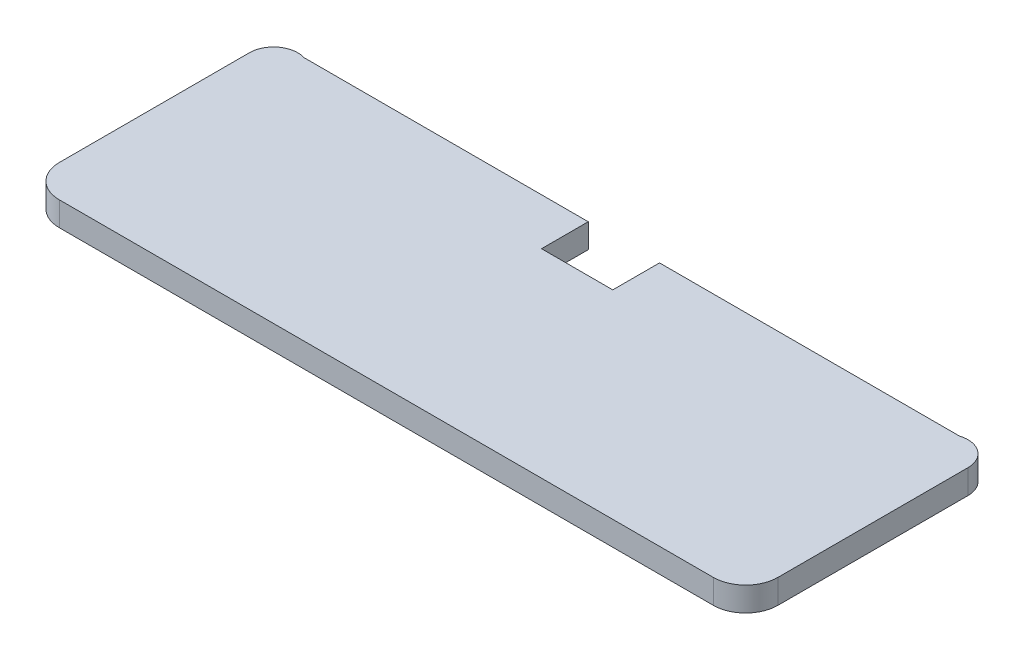
from build123d import *

# Parameters (mm, degrees)
RESSALTO_EXTRUS_O1_DEPTH = 3


with BuildPart() as part:
    # Esboço1 → Ressalto-extrusão1 (new body)
    with BuildSketch(Plane(origin=(0, 0, 0), x_dir=(1, 0, 0), z_dir=(0, 1, 0))):
        with BuildLine():
            Line((37.16356961, 16.484544918), (0, 16.484544918))
            Line((0, 16.484544918), (0, 10.69506871))
            Line((0, 10.69506871), (-8.827691361, 10.69506871))
            Line((-8.827691361, 10.69506871), (-8.827691361, 16.484544918))
            Line((-8.827691361, 16.484544918), (-44.03643039, 16.484544918))
            ThreePointArc((-44.03643039, 16.484544918), (-46.711254325, 16.041404638), (-47.93643039, 13.622727314))
            Line((-47.93643039, 13.622727314), (-47.93643039, 4.0833353))
            Line((-47.93643039, 4.0833353), (-47.93643039, -9.9166647))
            ThreePointArc((-47.93643039, -9.9166647), (-46.764857515, -12.745091825), (-43.93643039, -13.9166647))
            Line((-43.93643039, -13.9166647), (37.06356961, -13.9166647))
            ThreePointArc((37.06356961, -13.9166647), (39.891996735, -12.745091825), (41.06356961, -9.9166647))
            Line((41.06356961, -9.9166647), (41.06356961, 4.0833353))
            Line((41.06356961, 4.0833353), (41.06356961, 13.622727314))
            ThreePointArc((41.06356961, 13.622727314), (39.838393545, 16.041404638), (37.16356961, 16.484544918))
        make_face()
    extrude(amount=RESSALTO_EXTRUS_O1_DEPTH)


solid = part.part
